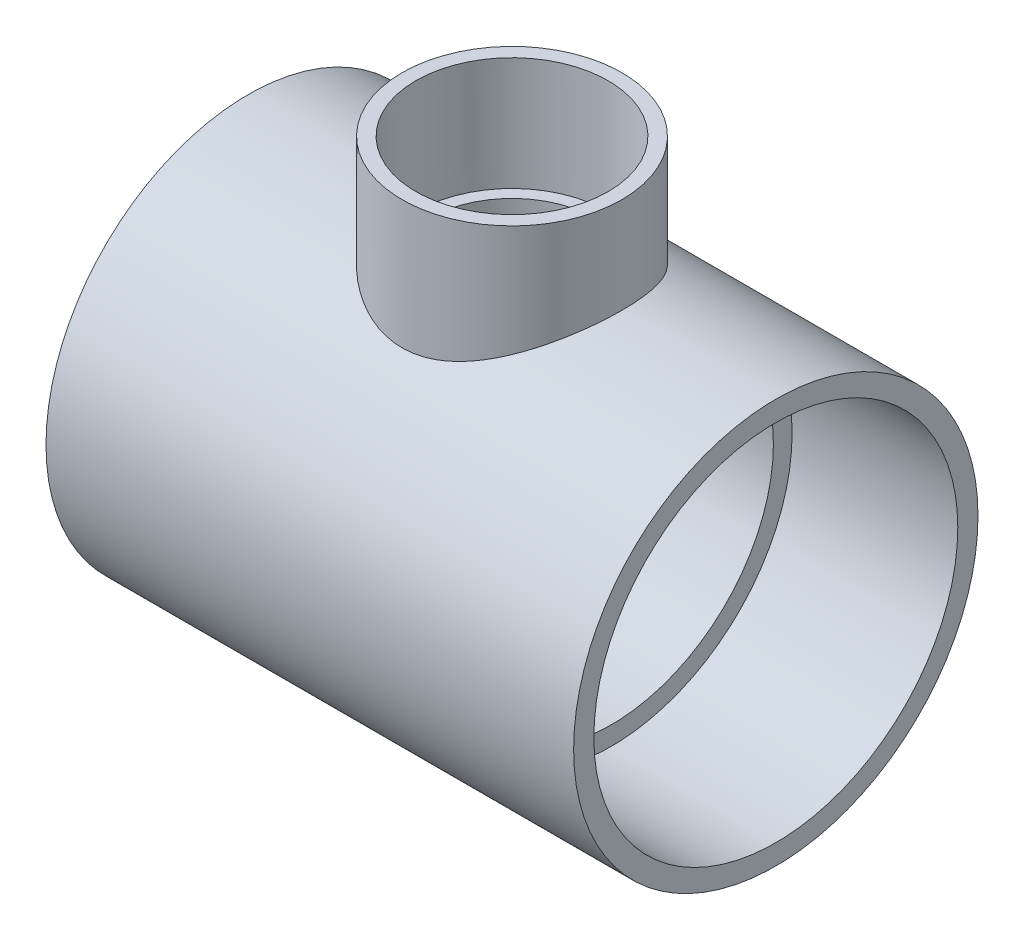
from build123d import *

# Parameters (mm, degrees)
SKETCH4_R           = 63.754
BOSS_EXTRUDE1_DEPTH = 62.5856
SKETCH5_R           = 34.671
BOSS_EXTRUDE2_DEPTH = 58.42


with BuildPart() as part:
    # Sketch1 → Revolve1 (revolve)
    with BuildSketch(Plane.XY):
        Polygon((-83.185, -63.754), (-31.2928, -63.754), (-31.2928, -57.0357), (-83.185, -57.3786), align=None)
        Polygon((83.185, -57.3786), (31.2928, -57.0357), (31.2928, -63.754), (83.185, -63.754), align=None)
    revolve(axis=Axis((-83.185, 0, 0), (1, 0, 0)))



with BuildPart() as body_2:
    # Sketch2 → Revolve2 (revolve)
    with BuildSketch(Plane.XY):
        Polygon((30.3149, 93.98), (30.0863, 58.42), (34.671, 58.42), (34.671, 93.98), align=None)
    revolve(axis=Axis((0, 0, 0), (0, 1, 0)))


with BuildPart() as part_1:
    add(part.part)

    add(body_2.part)  # Boss-Extrude1 merges body 2
    # Sketch4 → Boss-Extrude1 (add)
    with BuildSketch(Plane(origin=(-31.2928, 0, 0), x_dir=(0, 0, -1), z_dir=(1, 0, 0))):
        Circle(SKETCH4_R)
    extrude(amount=BOSS_EXTRUDE1_DEPTH)

    # Sketch5 → Boss-Extrude2 (add)
    with BuildSketch(Plane.XZ.offset(-58.42)):
        Circle(SKETCH5_R)
    extrude(amount=BOSS_EXTRUDE2_DEPTH)

    # Sketch6 → Cut-Revolve1 (revolve, cut)
    with BuildSketch(Plane.XY):
        Polygon((-83.185, -57.3786), (-31.2928, -57.0357), (-31.2928, -51.1302), (31.2928, -51.1302), (31.2928, -57.0357), (83.185, -57.3786), (83.185, 0), (-83.185, 0), align=None)
    revolve(axis=Axis((83.185, 0, 0), (-1, 0, 0)), mode=Mode.SUBTRACT)

    # Sketch7 → Cut-Revolve2 (revolve, cut)
    with BuildSketch(Plane.XY):
        Polygon((30.3149, 93.98), (30.0863, 58.42), (26.2509, 58.42), (26.2509, 0), (0, 0), (0, 93.98), align=None)
    revolve(axis=Axis((0, 0, 0), (0, 1, 0)), mode=Mode.SUBTRACT)


solid = part_1.part
